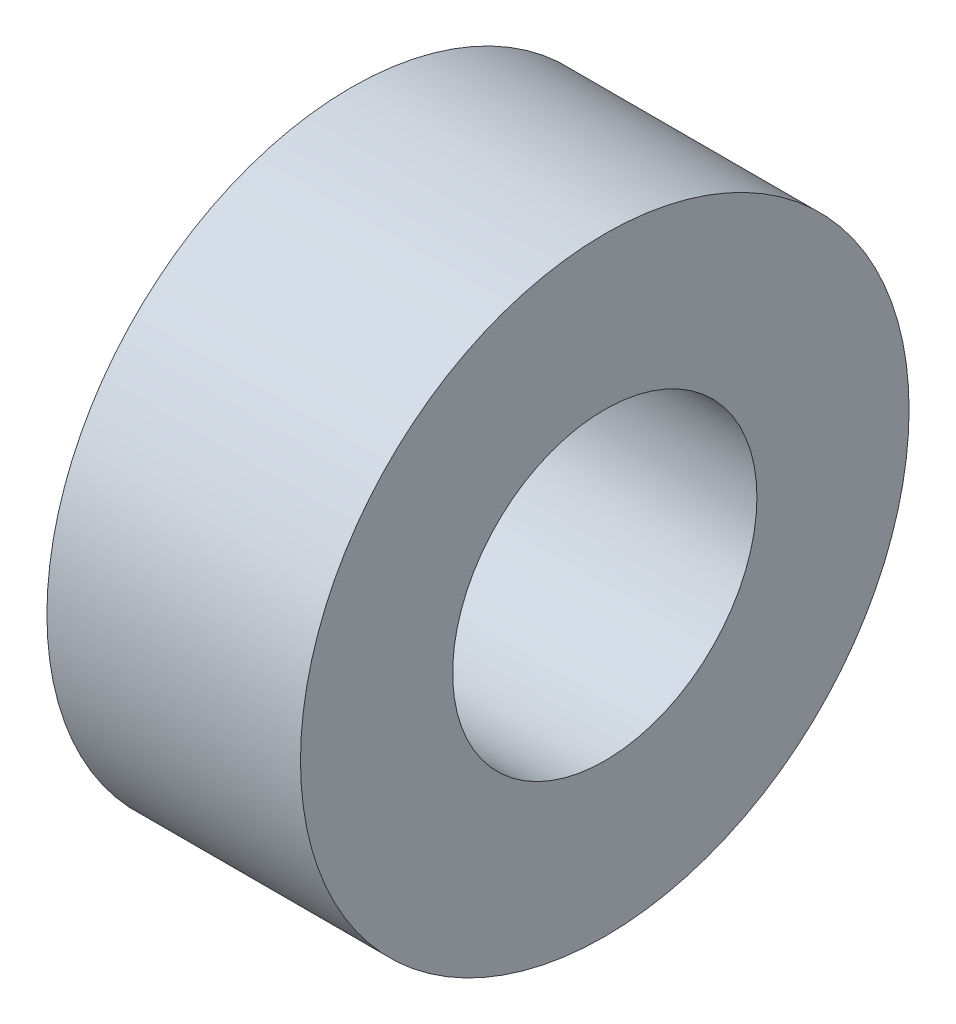
from build123d import *

# Parameters (mm, degrees)
SKETCH1_W = 2.5
SKETCH1_H = 1.5


with BuildPart() as part:
    # Sketch1 → Revolve1 (revolve)
    with BuildSketch(Plane(origin=(0, 0, 0), x_dir=(-1, 0, 0), z_dir=(0, 0, -1))):
        with Locations((0, 2.25)):
            Rectangle(SKETCH1_W, SKETCH1_H)
    revolve(axis=Axis((2.895672476, 0, 0), (-1, 0, 0)))


solid = part.part
